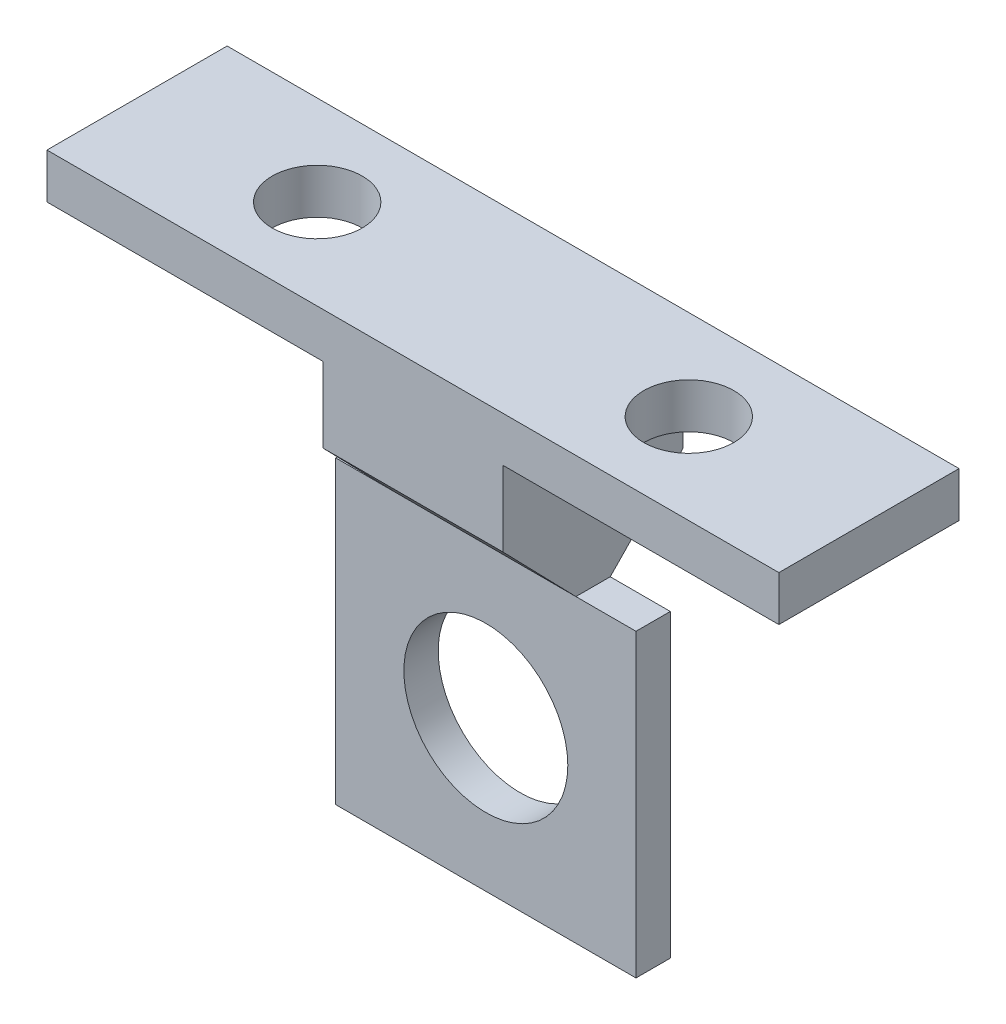
from build123d import *

# Parameters (mm, degrees)
SALIENTE_EXTRUIR1_DEPTH = 2.286
CROQUIS3_W              = 12
CROQUIS3_H              = 3
SALIENTE_EXTRUIR2_DEPTH = 48.748737
SALIENTE_EXTRUIR3_DEPTH = 12
CROQUIS5_R              = 5.46
CORTAR_EXTRUIR1_DEPTH   = 8.143
CROQUIS6_R              = 3
CORTAR_EXTRUIR2_DEPTH   = 3


with BuildPart() as part:
    # Croquis1 → Saliente-Extruir1 (new body)
    with BuildSketch(Plane.XY):
        Polygon((-14.666527812, 16.476832902), (-63.415265152, 16.476832902), (-63.415265152, 13.476832902), (-45.040896482, 13.476832902), (-45.040896482, 8.476832902), (-45.040896482, 3.476832902), (-49.040896482, 3.476832902), (-49.040896482, -16.523167098), (-29.040896482, -16.523167098), (-29.040896482, 3.476832902), (-33.040896482, 3.476832902), (-33.040896482, 8.476832902), (-33.040896482, 13.476832902), (-14.666527812, 13.476832902), align=None)
    extrude(amount=SALIENTE_EXTRUIR1_DEPTH)

    # Croquis3 → Saliente-Extruir2 (add)
    with BuildSketch(Plane.ZY.offset(63.415265152)):
        with Locations((1.143, 14.976832902)):
            Rectangle(CROQUIS3_W, CROQUIS3_H)
    extrude(amount=-SALIENTE_EXTRUIR2_DEPTH)

    # Croquis4 → Saliente-Extruir3 (add)
    with BuildSketch(Plane(origin=(-33.040896482, 0, 0), x_dir=(0, 0, -1), z_dir=(1, 0, 0))):
        Polygon((4.857, 8.476832902), (0, 3.476832902), (-2.286, 3.476832902), (-7.143, 8.476832902), (-7.143, 13.476832902), (4.857, 13.476832902), align=None)
    extrude(amount=-SALIENTE_EXTRUIR3_DEPTH)

    # Croquis5 → Cortar-Extruir1 (cut, through all)
    with BuildSketch(Plane.XY.offset(2.286)):
        with Locations((-39.040896482, -6.523167098)):
            Circle(CROQUIS5_R)
    extrude(amount=-CORTAR_EXTRUIR1_DEPTH, mode=Mode.SUBTRACT)

    # Croquis6 → Cortar-Extruir2 (cut)
    with BuildSketch(Plane(origin=(0, 16.476832902, 0), x_dir=(1, 0, 0), z_dir=(0, 1, 0))):
        with Locations((-26.666527812, -1.143)):
            Circle(CROQUIS6_R)
        with Locations((-51.415265152, -1.143)):
            Circle(CROQUIS6_R)
    extrude(amount=-CORTAR_EXTRUIR2_DEPTH, mode=Mode.SUBTRACT)


solid = part.part
